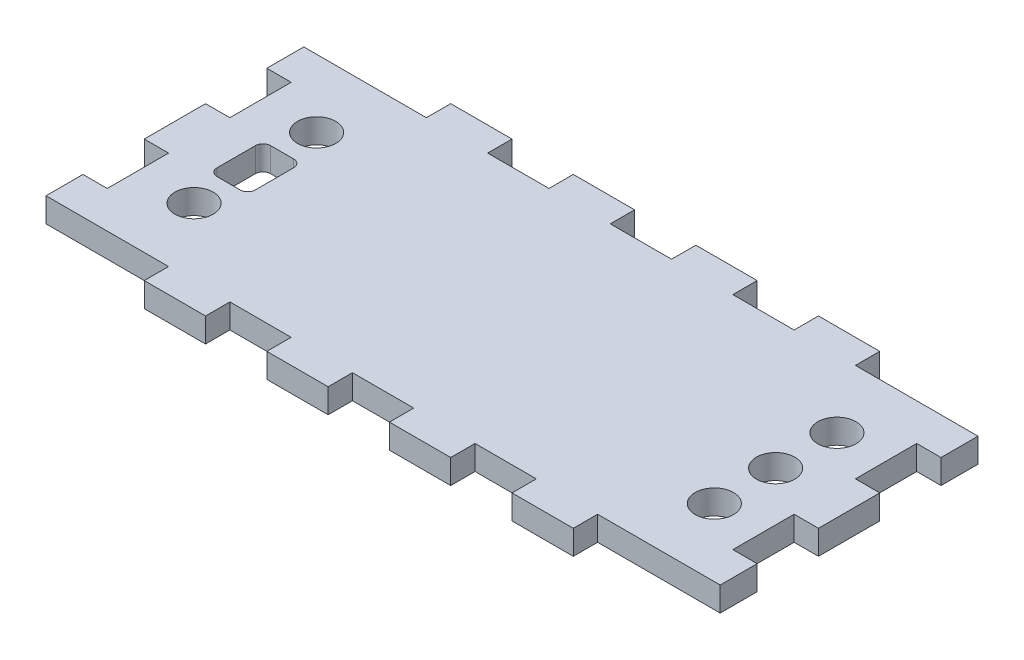
from build123d import *

# Parameters (mm, degrees)
SKETCH1_W           = 88
SKETCH1_H           = 40
BOSS_EXTRUDE1_DEPTH = 3.175
CUT_EXTRUDE1_REACH  = 5.175
SKETCH2_W           = 16
SKETCH2_H           = 3.175
SKETCH2_W_2         = 8
CUT_EXTRUDE2_REACH  = 5.175
SKETCH3_W           = 3.175
SKETCH3_H           = 8
CUT_EXTRUDE3_REACH  = 5.175
SKETCH4_R           = 2.5
CUT_EXTRUDE4_REACH  = 5.175
SKETCH5_R           = 2.5


with BuildPart() as part:
    # Sketch1 → Boss-Extrude1 (new body)
    with BuildSketch(Plane(origin=(0, 0, 0), x_dir=(1, 0, 0), z_dir=(0, 1, 0))):
        with Locations((44, -20)):
            Rectangle(SKETCH1_W, SKETCH1_H)
    extrude(amount=BOSS_EXTRUDE1_DEPTH)

    # Sketch2 → Cut-Extrude1 (cut, up to next)
    with BuildSketch(Plane(origin=(0, 3.175, 0), x_dir=(1, 0, 0), z_dir=(0, 1, 0)), mode=Mode.PRIVATE) as cut_extrude1_sk1:
        with Locations((8, -1.5875)):
            Rectangle(SKETCH2_W, SKETCH2_H)
    cut_extrude1_tool1 = extrude(cut_extrude1_sk1.sketch, amount=-CUT_EXTRUDE1_REACH, mode=Mode.PRIVATE) & part.part
    add(cut_extrude1_tool1.solids().sort_by_distance((8, 3.175, 1.5875))[0], mode=Mode.SUBTRACT)
    # Sketch2 → Cut-Extrude1 (cut, up to next)
    with BuildSketch(Plane(origin=(0, 3.175, 0), x_dir=(1, 0, 0), z_dir=(0, 1, 0)), mode=Mode.PRIVATE) as cut_extrude1_sk2:
        with Locations((44, -1.5875)):
            Rectangle(SKETCH2_W_2, SKETCH2_H)
    cut_extrude1_tool2 = extrude(cut_extrude1_sk2.sketch, amount=-CUT_EXTRUDE1_REACH, mode=Mode.PRIVATE) & part.part
    add(cut_extrude1_tool2.solids().sort_by_distance((44, 3.175, 1.5875))[0], mode=Mode.SUBTRACT)
    # Sketch2 → Cut-Extrude1 (cut, up to next)
    with BuildSketch(Plane(origin=(0, 3.175, 0), x_dir=(1, 0, 0), z_dir=(0, 1, 0)), mode=Mode.PRIVATE) as cut_extrude1_sk3:
        with Locations((60, -1.5875)):
            Rectangle(SKETCH2_W_2, SKETCH2_H)
    cut_extrude1_tool3 = extrude(cut_extrude1_sk3.sketch, amount=-CUT_EXTRUDE1_REACH, mode=Mode.PRIVATE) & part.part
    add(cut_extrude1_tool3.solids().sort_by_distance((60, 3.175, 1.5875))[0], mode=Mode.SUBTRACT)
    # Sketch2 → Cut-Extrude1 (cut, up to next)
    with BuildSketch(Plane(origin=(0, 3.175, 0), x_dir=(1, 0, 0), z_dir=(0, 1, 0)), mode=Mode.PRIVATE) as cut_extrude1_sk4:
        with Locations((80, -1.5875)):
            Rectangle(SKETCH2_W, SKETCH2_H)
    cut_extrude1_tool4 = extrude(cut_extrude1_sk4.sketch, amount=-CUT_EXTRUDE1_REACH, mode=Mode.PRIVATE) & part.part
    add(cut_extrude1_tool4.solids().sort_by_distance((80, 3.175, 1.5875))[0], mode=Mode.SUBTRACT)
    # Sketch2 → Cut-Extrude1 (cut, up to next)
    with BuildSketch(Plane(origin=(0, 3.175, 0), x_dir=(1, 0, 0), z_dir=(0, 1, 0)), mode=Mode.PRIVATE) as cut_extrude1_sk5:
        with Locations((28, -1.5875)):
            Rectangle(SKETCH2_W_2, SKETCH2_H)
    cut_extrude1_tool5 = extrude(cut_extrude1_sk5.sketch, amount=-CUT_EXTRUDE1_REACH, mode=Mode.PRIVATE) & part.part
    add(cut_extrude1_tool5.solids().sort_by_distance((28, 3.175, 1.5875))[0], mode=Mode.SUBTRACT)
    # Sketch2 → Cut-Extrude1 (cut, up to next)
    with BuildSketch(Plane(origin=(0, 3.175, 0), x_dir=(1, 0, 0), z_dir=(0, 1, 0)), mode=Mode.PRIVATE) as cut_extrude1_sk6:
        with Locations((44, -38.4125)):
            Rectangle(SKETCH2_W_2, SKETCH2_H)
    cut_extrude1_tool6 = extrude(cut_extrude1_sk6.sketch, amount=-CUT_EXTRUDE1_REACH, mode=Mode.PRIVATE) & part.part
    add(cut_extrude1_tool6.solids().sort_by_distance((44, 3.175, 38.4125))[0], mode=Mode.SUBTRACT)
    # Sketch2 → Cut-Extrude1 (cut, up to next)
    with BuildSketch(Plane(origin=(0, 3.175, 0), x_dir=(1, 0, 0), z_dir=(0, 1, 0)), mode=Mode.PRIVATE) as cut_extrude1_sk7:
        with Locations((28, -38.4125)):
            Rectangle(SKETCH2_W_2, SKETCH2_H)
    cut_extrude1_tool7 = extrude(cut_extrude1_sk7.sketch, amount=-CUT_EXTRUDE1_REACH, mode=Mode.PRIVATE) & part.part
    add(cut_extrude1_tool7.solids().sort_by_distance((28, 3.175, 38.4125))[0], mode=Mode.SUBTRACT)
    # Sketch2 → Cut-Extrude1 (cut, up to next)
    with BuildSketch(Plane(origin=(0, 3.175, 0), x_dir=(1, 0, 0), z_dir=(0, 1, 0)), mode=Mode.PRIVATE) as cut_extrude1_sk8:
        with Locations((8, -38.4125)):
            Rectangle(SKETCH2_W, SKETCH2_H)
    cut_extrude1_tool8 = extrude(cut_extrude1_sk8.sketch, amount=-CUT_EXTRUDE1_REACH, mode=Mode.PRIVATE) & part.part
    add(cut_extrude1_tool8.solids().sort_by_distance((8, 3.175, 38.4125))[0], mode=Mode.SUBTRACT)
    # Sketch2 → Cut-Extrude1 (cut, up to next)
    with BuildSketch(Plane(origin=(0, 3.175, 0), x_dir=(1, 0, 0), z_dir=(0, 1, 0)), mode=Mode.PRIVATE) as cut_extrude1_sk9:
        with Locations((80, -38.4125)):
            Rectangle(SKETCH2_W, SKETCH2_H)
    cut_extrude1_tool9 = extrude(cut_extrude1_sk9.sketch, amount=-CUT_EXTRUDE1_REACH, mode=Mode.PRIVATE) & part.part
    add(cut_extrude1_tool9.solids().sort_by_distance((80, 3.175, 38.4125))[0], mode=Mode.SUBTRACT)
    # Sketch2 → Cut-Extrude1 (cut, up to next)
    with BuildSketch(Plane(origin=(0, 3.175, 0), x_dir=(1, 0, 0), z_dir=(0, 1, 0)), mode=Mode.PRIVATE) as cut_extrude1_sk10:
        with Locations((60, -38.4125)):
            Rectangle(SKETCH2_W_2, SKETCH2_H)
    cut_extrude1_tool10 = extrude(cut_extrude1_sk10.sketch, amount=-CUT_EXTRUDE1_REACH, mode=Mode.PRIVATE) & part.part
    add(cut_extrude1_tool10.solids().sort_by_distance((60, 3.175, 38.4125))[0], mode=Mode.SUBTRACT)

    # Sketch3 → Cut-Extrude2 (cut, up to next)
    with BuildSketch(Plane(origin=(0, 3.175, 0), x_dir=(1, 0, 0), z_dir=(0, 1, 0)), mode=Mode.PRIVATE) as cut_extrude2_sk1:
        with Locations((1.5875, -28)):
            Rectangle(SKETCH3_W, SKETCH3_H)
    cut_extrude2_tool1 = extrude(cut_extrude2_sk1.sketch, amount=-CUT_EXTRUDE2_REACH, mode=Mode.PRIVATE) & part.part
    add(cut_extrude2_tool1.solids().sort_by_distance((1.5875, 3.175, 28))[0], mode=Mode.SUBTRACT)
    # Sketch3 → Cut-Extrude2 (cut, up to next)
    with BuildSketch(Plane(origin=(0, 3.175, 0), x_dir=(1, 0, 0), z_dir=(0, 1, 0)), mode=Mode.PRIVATE) as cut_extrude2_sk2:
        with Locations((1.5875, -12)):
            Rectangle(SKETCH3_W, SKETCH3_H)
    cut_extrude2_tool2 = extrude(cut_extrude2_sk2.sketch, amount=-CUT_EXTRUDE2_REACH, mode=Mode.PRIVATE) & part.part
    add(cut_extrude2_tool2.solids().sort_by_distance((1.5875, 3.175, 12))[0], mode=Mode.SUBTRACT)
    # Sketch3 → Cut-Extrude2 (cut, up to next)
    with BuildSketch(Plane(origin=(0, 3.175, 0), x_dir=(1, 0, 0), z_dir=(0, 1, 0)), mode=Mode.PRIVATE) as cut_extrude2_sk3:
        with Locations((86.4125, -28)):
            Rectangle(SKETCH3_W, SKETCH3_H)
    cut_extrude2_tool3 = extrude(cut_extrude2_sk3.sketch, amount=-CUT_EXTRUDE2_REACH, mode=Mode.PRIVATE) & part.part
    add(cut_extrude2_tool3.solids().sort_by_distance((86.4125, 3.175, 28))[0], mode=Mode.SUBTRACT)
    # Sketch3 → Cut-Extrude2 (cut, up to next)
    with BuildSketch(Plane(origin=(0, 3.175, 0), x_dir=(1, 0, 0), z_dir=(0, 1, 0)), mode=Mode.PRIVATE) as cut_extrude2_sk4:
        with Locations((86.4125, -12)):
            Rectangle(SKETCH3_W, SKETCH3_H)
    cut_extrude2_tool4 = extrude(cut_extrude2_sk4.sketch, amount=-CUT_EXTRUDE2_REACH, mode=Mode.PRIVATE) & part.part
    add(cut_extrude2_tool4.solids().sort_by_distance((86.4125, 3.175, 12))[0], mode=Mode.SUBTRACT)

    # Sketch4 → Cut-Extrude3 (cut, up to next)
    with BuildSketch(Plane(origin=(0, 3.175, 0), x_dir=(1, 0, 0), z_dir=(0, 1, 0)), mode=Mode.PRIVATE) as cut_extrude3_sk1:
        with Locations((78.41, -28)):
            Circle(SKETCH4_R)
    cut_extrude3_tool1 = extrude(cut_extrude3_sk1.sketch, amount=-CUT_EXTRUDE3_REACH, mode=Mode.PRIVATE) & part.part
    add(cut_extrude3_tool1.solids().sort_by_distance((78.41, 3.175, 28))[0], mode=Mode.SUBTRACT)
    # Sketch4 → Cut-Extrude3 (cut, up to next)
    with BuildSketch(Plane(origin=(0, 3.175, 0), x_dir=(1, 0, 0), z_dir=(0, 1, 0)), mode=Mode.PRIVATE) as cut_extrude3_sk2:
        with Locations((78.41, -12)):
            Circle(SKETCH4_R)
    cut_extrude3_tool2 = extrude(cut_extrude3_sk2.sketch, amount=-CUT_EXTRUDE3_REACH, mode=Mode.PRIVATE) & part.part
    add(cut_extrude3_tool2.solids().sort_by_distance((78.41, 3.175, 12))[0], mode=Mode.SUBTRACT)
    # Sketch4 → Cut-Extrude3 (cut, up to next)
    with BuildSketch(Plane(origin=(0, 3.175, 0), x_dir=(1, 0, 0), z_dir=(0, 1, 0)), mode=Mode.PRIVATE) as cut_extrude3_sk3:
        with Locations((78.41, -20)):
            Circle(SKETCH4_R)
    cut_extrude3_tool3 = extrude(cut_extrude3_sk3.sketch, amount=-CUT_EXTRUDE3_REACH, mode=Mode.PRIVATE) & part.part
    add(cut_extrude3_tool3.solids().sort_by_distance((78.41, 3.175, 20))[0], mode=Mode.SUBTRACT)

    # Sketch5 → Cut-Extrude4 (cut, up to next)
    with BuildSketch(Plane(origin=(0, 3.175, 0), x_dir=(1, 0, 0), z_dir=(0, 1, 0)), mode=Mode.PRIVATE) as cut_extrude4_sk1:
        with Locations((10.5, -12)):
            Circle(SKETCH5_R)
    cut_extrude4_tool1 = extrude(cut_extrude4_sk1.sketch, amount=-CUT_EXTRUDE4_REACH, mode=Mode.PRIVATE) & part.part
    add(cut_extrude4_tool1.solids().sort_by_distance((10.5, 3.175, 12))[0], mode=Mode.SUBTRACT)
    # Sketch5 → Cut-Extrude4 (cut, up to next)
    with BuildSketch(Plane(origin=(0, 3.175, 0), x_dir=(1, 0, 0), z_dir=(0, 1, 0)), mode=Mode.PRIVATE) as cut_extrude4_sk2:
        with Locations((10.5, -28)):
            Circle(SKETCH5_R)
    cut_extrude4_tool2 = extrude(cut_extrude4_sk2.sketch, amount=-CUT_EXTRUDE4_REACH, mode=Mode.PRIVATE) & part.part
    add(cut_extrude4_tool2.solids().sort_by_distance((10.5, 3.175, 28))[0], mode=Mode.SUBTRACT)
    # Sketch5 → Cut-Extrude4 (cut, up to next)
    with BuildSketch(Plane(origin=(0, 3.175, 0), x_dir=(1, 0, 0), z_dir=(0, 1, 0)), mode=Mode.PRIVATE) as cut_extrude4_sk3:
        with BuildLine():
            Line((9, -16.5), (12, -16.5))
            ThreePointArc((12, -16.5), (12.707106781, -16.792893219), (13, -17.5))
            Line((13, -17.5), (13, -22.5))
            ThreePointArc((13, -22.5), (12.707106781, -23.207106781), (12, -23.5))
            Line((12, -23.5), (9, -23.5))
            ThreePointArc((9, -23.5), (8.292893219, -23.207106781), (8, -22.5))
            Line((8, -22.5), (8, -17.5))
            ThreePointArc((8, -17.5), (8.292893219, -16.792893219), (9, -16.5))
        make_face()
    cut_extrude4_tool3 = extrude(cut_extrude4_sk3.sketch, amount=-CUT_EXTRUDE4_REACH, mode=Mode.PRIVATE) & part.part
    add(cut_extrude4_tool3.solids().sort_by_distance((10.5, 3.175, 20))[0], mode=Mode.SUBTRACT)


solid = part.part
